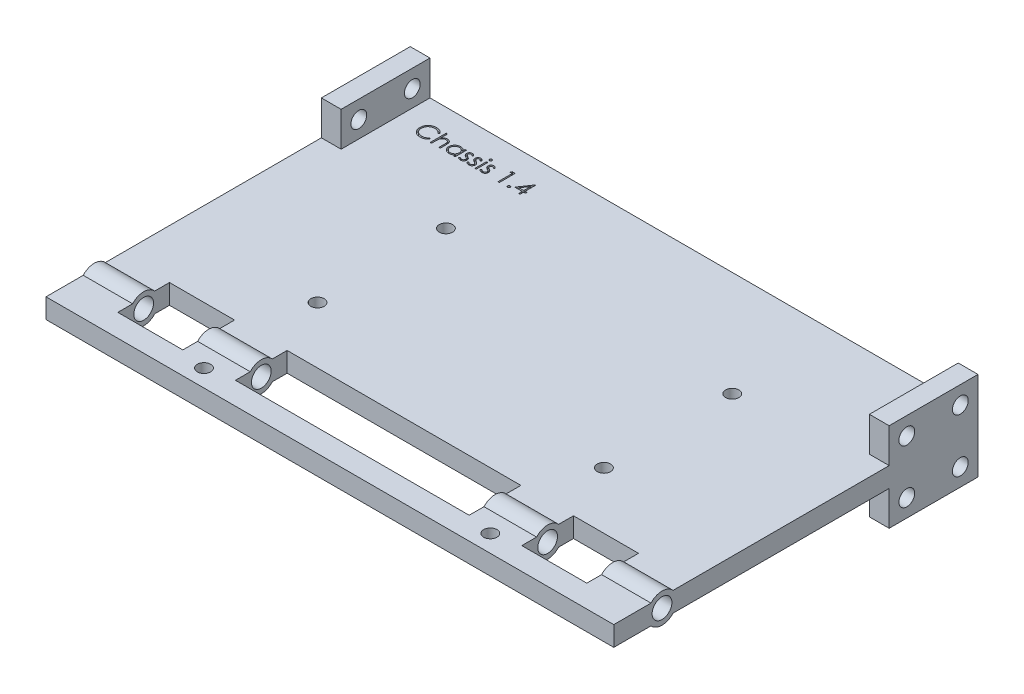
from build123d import *

# Parameters (mm, degrees)
SKETCH1_W           = 115
SKETCH1_H           = 73.776493944
SKETCH1_R           = 1.35
BASE_CHASSIS_DEPTH  = 2
SKETCH14_W          = 0.284935898
SKETCH14_H          = 2.320192308
TEXT_2_DEPTH        = 0.5
SKETCH7_W           = 18
SKETCH7_H           = 18
SKETCH7_R           = 1.6
MOUNT_HOLES_DEPTH   = 4
SKETCH8_R           = 3
SHAFT_EXTRUDE_DEPTH = 115
SKETCH20_R          = 2
SHAFT_CUT_DEPTH     = 116.0000001
SCREW_START         = -12
SCREW_HOLE_DEPTH    = 20


with BuildPart() as part:
    # Sketch1 → Base Chassis (new body, symmetric)
    with BuildSketch(Plane(origin=(0, 0, 0), x_dir=(1, 0, 0), z_dir=(0, 1, 0))):
        with Locations((57.5, -36.888246972)):
            Rectangle(SKETCH1_W, SKETCH1_H)
        with Locations((28.5, -47.276493944)):
            Circle(SKETCH1_R, mode=Mode.SUBTRACT)
        with Locations((28.5, -70.276493944)):
            Circle(SKETCH1_R, mode=Mode.SUBTRACT)
        with Locations((86.5, -47.276493944)):
            Circle(SKETCH1_R, mode=Mode.SUBTRACT)
        with Locations((86.5, -70.276493944)):
            Circle(SKETCH1_R, mode=Mode.SUBTRACT)
        with Locations((86.5, -21.276493944)):
            Circle(SKETCH1_R, mode=Mode.SUBTRACT)
        with Locations((28.5, -21.276493944)):
            Circle(SKETCH1_R, mode=Mode.SUBTRACT)
    extrude(amount=BASE_CHASSIS_DEPTH, both=True)

    # Sketch14 → Text 2 (cut)
    with BuildSketch(Plane(origin=(0, 2, 0), x_dir=(1, 0, 0), z_dir=(0, 1, 0))):
        with BuildLine():
            Line((11.257646665, -5.20350905), (11.008327754, -5.394314339))
            add(Edge.make_bspline(
                [(11.008327754, -5.394314339), (10.990542413, -5.373118066), (10.955211515, -5.331011293), (10.898370667, -5.271884134), (10.839132748, -5.216489219), (10.777520402, -5.164562656), (10.712424629, -5.117920305), (10.645422334, -5.074131518), (10.575392678, -5.034881499), (10.478553605, -4.987290076), (10.351873057, -4.937627492), (10.192402024, -4.895986704), (10.025931242, -4.869478923), (9.912359134, -4.86660796), (9.854591777, -4.865147672)],
                knots=[0, 0, 0, 0, 8.299e-05, 0.000164861, 0.000245858, 0.000326233, 0.000406381, 0.000485944, 0.000566254, 0.000647036, 0.000809554, 0.000973391, 0.001140702, 0.001313896, 0.001313896, 0.001313896, 0.001313896], degree=3))
            add(Edge.make_bspline(
                [(9.854591777, -4.865147672), (9.822766213, -4.865514124), (9.759410455, -4.866243626), (9.665386483, -4.875867618), (9.573118215, -4.889394216), (9.48266567, -4.909465045), (9.394143987, -4.934840207), (9.30697445, -4.965161832), (9.222419121, -5.00267658), (9.13930829, -5.044140501), (9.059680006, -5.090973969), (8.984337213, -5.142058224), (8.913554699, -5.196821618), (8.847276472, -5.255469408), (8.785434776, -5.317737472), (8.728477716, -5.38428941), (8.676602379, -5.454912454), (8.628780506, -5.52867533), (8.585951813, -5.605363184), (8.550092565, -5.685259855), (8.518337918, -5.766997149), (8.493210748, -5.851498559), (8.473322079, -5.938169496), (8.459599128, -6.027242568), (8.450084586, -6.118531692), (8.449358711, -6.180407283), (8.448992819, -6.211596991)],
                knots=[0, 0, 0, 0, 9.5437e-05, 0.000189987, 0.000283265, 0.000375086, 0.000467691, 0.000559419, 0.000651703, 0.000744998, 0.000837935, 0.000928607, 0.001017915, 0.001106228, 0.001193927, 0.001280987, 0.00136876, 0.001456615, 0.001544584, 0.001631962, 0.001719133, 0.001807466, 0.001896183, 0.00198569, 0.002077709, 0.002171238, 0.002171238, 0.002171238, 0.002171238], degree=3))
            add(Edge.make_bspline(
                [(8.448992819, -6.211596991), (8.450137469, -6.258524688), (8.452384837, -6.350660998), (8.472385826, -6.485617194), (8.50277973, -6.614903805), (8.548332432, -6.737712662), (8.604501857, -6.855558101), (8.675477269, -6.966446204), (8.757679413, -7.072052659), (8.852271208, -7.169881619), (8.956053627, -7.259247641), (9.067403518, -7.337942812), (9.186043551, -7.403542741), (9.310663779, -7.458130921), (9.442223183, -7.500092381), (9.580485182, -7.529632693), (9.725149063, -7.548902385), (9.823999876, -7.550747231), (9.874308323, -7.551686134)],
                knots=[0, 0, 0, 0, 0.000140704, 0.000276253, 0.000408455, 0.000538433, 0.000668431, 0.000799358, 0.000932567, 0.001069312, 0.00120687, 0.001342915, 0.001477586, 0.00161288, 0.00175046, 0.001891054, 0.002036604, 0.002187448, 0.002187448, 0.002187448, 0.002187448], degree=3))
            add(Edge.make_bspline(
                [(9.874308323, -7.551686134), (9.929737191, -7.550154169), (10.038834463, -7.547138897), (10.198825458, -7.521594435), (10.351983617, -7.480176181), (10.498317178, -7.422211637), (10.637413607, -7.346859554), (10.769490577, -7.255512194), (10.894659573, -7.147300635), (10.969926379, -7.064675226), (11.008327754, -7.022519467)],
                knots=[0, 0, 0, 0, 0.000166206, 0.000327134, 0.000484664, 0.00064139, 0.000798189, 0.000958205, 0.001122325, 0.001293282, 0.001293282, 0.001293282, 0.001293282], degree=3))
            Line((11.008327754, -7.022519467), (11.257646665, -7.211416703))
            add(Edge.make_bspline(
                [(11.257646665, -7.211416703), (11.237582379, -7.237305155), (11.197549915, -7.288958057), (11.132727286, -7.361775965), (11.064440023, -7.430268911), (10.992180915, -7.493884682), (10.916781204, -7.553896233), (10.836887035, -7.608598609), (10.753548698, -7.658755339), (10.667048564, -7.704681192), (10.577478536, -7.745427552), (10.484945942, -7.780310613), (10.389849634, -7.81035962), (10.292185266, -7.835081019), (10.191750258, -7.854376931), (10.088907042, -7.867276208), (9.983433655, -7.876113516), (9.91227608, -7.876918982), (9.876216376, -7.877327159)],
                knots=[0, 0, 0, 0, 9.8237e-05, 0.000196004, 0.000292247, 0.000388218, 0.000484669, 0.00058117, 0.000678466, 0.000776338, 0.000874822, 0.000973456, 0.001072826, 0.001173865, 0.001275526, 0.001379423, 0.001484691, 0.001592844, 0.001592844, 0.001592844, 0.001592844], degree=3))
            add(Edge.make_bspline(
                [(9.876216376, -7.877327159), (9.842068193, -7.877089495), (9.774544388, -7.876619542), (9.67485052, -7.869006647), (9.577795686, -7.8586201), (9.483657276, -7.842980839), (9.39192157, -7.824525616), (9.303420183, -7.79978669), (9.217282242, -7.772074232), (9.133853818, -7.73950328), (9.053063948, -7.702749314), (8.975173205, -7.661209829), (8.900217412, -7.615234137), (8.827459638, -7.565835663), (8.757974687, -7.511427682), (8.691160417, -7.452765807), (8.626642171, -7.390047754), (8.58672545, -7.34482228), (8.56665608, -7.32208377)],
                knots=[0, 0, 0, 0, 0.000102417, 0.000202516, 0.000299794, 0.000395154, 0.000488707, 0.000580357, 0.000670665, 0.000760075, 0.000848874, 0.000936794, 0.001024712, 0.001112565, 0.001200478, 0.001289268, 0.001379219, 0.001470177, 0.001470177, 0.001470177, 0.001470177], degree=3))
            add(Edge.make_bspline(
                [(8.56665608, -7.32208377), (8.534510889, -7.282585691), (8.470608592, -7.20406639), (8.388851722, -7.076806964), (8.318867868, -6.943939374), (8.262283997, -6.804765582), (8.218049232, -6.659597881), (8.187404862, -6.508363093), (8.167491621, -6.351202459), (8.165214431, -6.244307658), (8.164056921, -6.189972392)],
                knots=[0, 0, 0, 0, 0.000152677, 0.000303511, 0.000452867, 0.000602629, 0.000753527, 0.000907451, 0.001065071, 0.001228016, 0.001228016, 0.001228016, 0.001228016], degree=3))
            add(Edge.make_bspline(
                [(8.164056921, -6.189972392), (8.165467704, -6.132862802), (8.168243331, -6.020503249), (8.191825231, -5.855608305), (8.229760853, -5.697628108), (8.283642316, -5.546857568), (8.351955028, -5.402503671), (8.436343456, -5.265669149), (8.535827221, -5.13547891), (8.649626086, -5.013908385), (8.774419312, -4.902747687), (8.908058521, -4.804952059), (9.050282145, -4.723565455), (9.199523339, -4.655533222), (9.356899636, -4.603241459), (9.522075263, -4.566635354), (9.69473985, -4.543850542), (9.812543622, -4.540970175), (9.872400271, -4.539506646)],
                knots=[0, 0, 0, 0, 0.000171259, 0.000336941, 0.000498606, 0.000657931, 0.000816392, 0.000976852, 0.001139297, 0.001307149, 0.001475639, 0.001640004, 0.001802988, 0.001966374, 0.002131298, 0.002299486, 0.002473278, 0.002652798, 0.002652798, 0.002652798, 0.002652798], degree=3))
            add(Edge.make_bspline(
                [(9.872400271, -4.539506646), (9.908880541, -4.539944015), (9.981089564, -4.540809741), (10.087908042, -4.549251741), (10.19190501, -4.563324798), (10.293152115, -4.58248009), (10.392141917, -4.606253875), (10.488117849, -4.637224003), (10.581643087, -4.672635713), (10.672127782, -4.713419464), (10.759137795, -4.759200008), (10.842646027, -4.809469895), (10.921989149, -4.864166805), (10.997725461, -4.922825542), (11.068588024, -4.986687093), (11.136588794, -5.053994912), (11.199418487, -5.126687738), (11.238201742, -5.177855071), (11.257646665, -5.20350905)],
                knots=[0, 0, 0, 0, 0.000109425, 0.000216595, 0.000321206, 0.000424117, 0.000525619, 0.000626393, 0.000726442, 0.000825506, 0.000923941, 0.001021237, 0.001117738, 0.001212903, 0.001308399, 0.001403742, 0.001499772, 0.001596332, 0.001596332, 0.001596332, 0.001596332], degree=3))
        make_face()
        with BuildLine():
            Line((11.82751846, -4.539506646), (12.112454357, -4.539506646))
            Line((12.112454357, -4.539506646), (12.112454357, -5.913940741))
            add(Edge.make_bspline(
                [(12.112454357, -5.913940741), (12.143040766, -5.875710129), (12.202594073, -5.801273167), (12.302829836, -5.704153373), (12.405764127, -5.619971767), (12.514952204, -5.552960709), (12.628390891, -5.500022988), (12.746558625, -5.46247848), (12.869477363, -5.439390699), (12.952957321, -5.436489277), (12.995246825, -5.435019467)],
                knots=[0, 0, 0, 0, 0.000146744, 0.000285718, 0.000417826, 0.00054491, 0.000668979, 0.000792481, 0.000915983, 0.001042781, 0.001042781, 0.001042781, 0.001042781], degree=3))
            add(Edge.make_bspline(
                [(12.995246825, -5.435019467), (13.038182253, -5.436602822), (13.122217242, -5.439701828), (13.244573997, -5.464206824), (13.358838505, -5.506078214), (13.464671091, -5.56337973), (13.559762066, -5.634747223), (13.643990067, -5.71714439), (13.712788505, -5.812642873), (13.759596276, -5.900868189), (13.790052153, -5.979371202), (13.809330595, -6.046714324), (13.825676582, -6.121754916), (13.839918486, -6.204454352), (13.849410449, -6.295209615), (13.857034638, -6.39361126), (13.862456136, -6.499653645), (13.862666234, -6.573059872), (13.86277487, -6.611016062)],
                knots=[0, 0, 0, 0, 0.000128741, 0.000251978, 0.000372501, 0.000492599, 0.000611662, 0.000728143, 0.000844672, 0.000963309, 0.001026736, 0.001096978, 0.001173207, 0.001257065, 0.001348583, 0.001446826, 0.001553163, 0.001667017, 0.001667017, 0.001667017, 0.001667017], degree=3))
            Line((13.86277487, -6.611016062), (13.86277487, -7.795916903))
            Line((13.86277487, -7.795916903), (13.577838972, -7.795916903))
            Line((13.577838972, -7.795916903), (13.577838972, -6.704510653))
            add(Edge.make_bspline(
                [(13.577838972, -6.704510653), (13.57766634, -6.672921517), (13.577336124, -6.612496876), (13.576244519, -6.525986192), (13.573807738, -6.447521841), (13.569869989, -6.377355292), (13.565728603, -6.315388724), (13.560028736, -6.261712124), (13.55339731, -6.216251771), (13.547438487, -6.188888143), (13.544766056, -6.176616021)],
                knots=[0, 0, 0, 0, 9.4769e-05, 0.000181277, 0.000259548, 0.000330249, 0.000392103, 0.000445834, 0.000492159, 0.000529829, 0.000529829, 0.000529829, 0.000529829], degree=3))
            add(Edge.make_bspline(
                [(13.544766056, -6.176616021), (13.534402633, -6.140607654), (13.514479014, -6.071381776), (13.468171206, -5.977345162), (13.410332675, -5.897167575), (13.339714088, -5.831931043), (13.257564715, -5.780757718), (13.16334889, -5.745317658), (13.057953342, -5.72332151), (12.983702364, -5.721108713), (12.945001432, -5.719955364)],
                knots=[0, 0, 0, 0, 0.000112235, 0.000215771, 0.000312707, 0.000407219, 0.000502346, 0.000601207, 0.000707732, 0.000823699, 0.000823699, 0.000823699, 0.000823699], degree=3))
            add(Edge.make_bspline(
                [(12.945001432, -5.719955364), (12.922079952, -5.720387007), (12.876718936, -5.721241216), (12.809455503, -5.729817253), (12.744205567, -5.743831447), (12.680340734, -5.76279485), (12.619214548, -5.788599016), (12.559045282, -5.818471402), (12.501537678, -5.855036747), (12.445670544, -5.896062979), (12.393675353, -5.941483404), (12.345300041, -5.989423142), (12.302175975, -6.040472574), (12.263106611, -6.093812679), (12.229380594, -6.150175092), (12.199941013, -6.209016295), (12.174962202, -6.27041367), (12.162550046, -6.313026761), (12.156339573, -6.334348393)],
                knots=[0, 0, 0, 0, 6.8737e-05, 0.000136029, 0.000203016, 0.000268809, 0.000335543, 0.000401817, 0.000470111, 0.000539693, 0.000609577, 0.000677037, 0.000743816, 0.000809842, 0.000875179, 0.000940599, 0.001007093, 0.001073681, 0.001073681, 0.001073681, 0.001073681], degree=3))
            add(Edge.make_bspline(
                [(12.156339573, -6.334348393), (12.15276595, -6.349788827), (12.144978585, -6.383435434), (12.136528701, -6.438929285), (12.128965128, -6.503414779), (12.122571086, -6.576794109), (12.11864943, -6.659336165), (12.11442374, -6.750477678), (12.112850741, -6.850789554), (12.112590434, -6.920544764), (12.112454357, -6.957009651)],
                knots=[0, 0, 0, 0, 4.7531e-05, 0.000103577, 0.000168266, 0.000242318, 0.000324485, 0.000416151, 0.000516024, 0.000625421, 0.000625421, 0.000625421, 0.000625421], degree=3))
            Line((12.112454357, -6.957009651), (12.112454357, -7.795916903))
            Line((12.112454357, -7.795916903), (11.82751846, -7.795916903))
            Line((11.82751846, -7.795916903), (11.82751846, -4.539506646))
        make_face()
        with BuildLine():
            Line((16.874954357, -5.475724595), (16.874954357, -7.795916903))
            Line((16.874954357, -7.795916903), (16.59001846, -7.795916903))
            Line((16.59001846, -7.795916903), (16.59001846, -7.394589779))
            add(Edge.make_bspline(
                [(16.59001846, -7.394589779), (16.557888557, -7.430911411), (16.495186647, -7.501793532), (16.390465062, -7.594396646), (16.279459643, -7.670939837), (16.162709159, -7.732761547), (16.040319038, -7.779200055), (15.912560587, -7.812207499), (15.779381692, -7.83342905), (15.688438484, -7.835548155), (15.642352194, -7.836622031)],
                knots=[0, 0, 0, 0, 0.000145381, 0.000283713, 0.000418146, 0.000549018, 0.000679067, 0.000809885, 0.000944361, 0.001082524, 0.001082524, 0.001082524, 0.001082524], degree=3))
            add(Edge.make_bspline(
                [(15.642352194, -7.836622031), (15.601378407, -7.835509536), (15.520576285, -7.833315647), (15.401714194, -7.816295557), (15.28733051, -7.788962779), (15.177317148, -7.750952687), (15.072385988, -7.700532941), (14.971638614, -7.640170523), (14.875596958, -7.56828777), (14.785724919, -7.486111488), (14.702964461, -7.396853178), (14.63033745, -7.301652575), (14.56978287, -7.200921342), (14.519146083, -7.095934838), (14.480142256, -6.985884875), (14.452951888, -6.871152016), (14.435951625, -6.751871916), (14.433758643, -6.670646777), (14.432646665, -6.629460573)],
                knots=[0, 0, 0, 0, 0.000122885, 0.000242334, 0.00035942, 0.00047528, 0.000590784, 0.00070804, 0.000827103, 0.000950019, 0.001072896, 0.001191833, 0.001308545, 0.001424896, 0.001540967, 0.001658053, 0.001778133, 0.001901653, 0.001901653, 0.001901653, 0.001901653], degree=3))
            add(Edge.make_bspline(
                [(14.432646665, -6.629460573), (14.433783289, -6.589125642), (14.436030333, -6.509385659), (14.45277004, -6.392111411), (14.480919598, -6.279155561), (14.520423717, -6.170881762), (14.571080347, -6.067159002), (14.632700826, -5.967913922), (14.705289603, -5.872873112), (14.788975716, -5.784271356), (14.879630829, -5.70242837), (14.97661232, -5.631300165), (15.077507725, -5.569871309), (15.183882028, -5.521199941), (15.294160759, -5.481821682), (15.40932567, -5.45457749), (15.528897602, -5.438523491), (15.610078263, -5.436198698), (15.65125644, -5.435019467)],
                knots=[0, 0, 0, 0, 0.000120979, 0.000239169, 0.000354553, 0.000469642, 0.000584275, 0.000700235, 0.000819557, 0.000942401, 0.001065363, 0.001185447, 0.001302704, 0.001419089, 0.001535759, 0.001653464, 0.001773457, 0.001896977, 0.001896977, 0.001896977, 0.001896977], degree=3))
            add(Edge.make_bspline(
                [(15.65125644, -5.435019467), (15.69860917, -5.436323713), (15.791465637, -5.438881278), (15.927290331, -5.460165323), (16.055782107, -5.496123076), (16.177932841, -5.545033949), (16.293303892, -5.610029582), (16.400803028, -5.692017118), (16.501555288, -5.79047948), (16.559957409, -5.866108384), (16.59001846, -5.905036494)],
                knots=[0, 0, 0, 0, 0.000142004, 0.000278464, 0.000411172, 0.000541562, 0.000672282, 0.000807119, 0.000946093, 0.001093501, 0.001093501, 0.001093501, 0.001093501], degree=3))
            Line((16.59001846, -5.905036494), (16.59001846, -5.475724595))
            Line((16.59001846, -5.475724595), (16.874954357, -5.475724595))
        make_face()
        with BuildLine():
            add(Edge.make_bspline(
                [(15.655072546, -5.719955364), (15.613421683, -5.721437307), (15.531209503, -5.724362427), (15.410519586, -5.747198383), (15.295028132, -5.785193694), (15.185312765, -5.837156561), (15.083106597, -5.902496915), (14.991763053, -5.981528456), (14.910535031, -6.07209489), (14.842219677, -6.173787519), (14.786529726, -6.282806215), (14.747371061, -6.396765527), (14.721545387, -6.513610042), (14.718906943, -6.592860479), (14.717582562, -6.632640661)],
                knots=[0, 0, 0, 0, 0.000124893, 0.000246519, 0.000366995, 0.00048876, 0.000609786, 0.000729752, 0.00085002, 0.00097368, 0.001096273, 0.001216155, 0.001334406, 0.001453586, 0.001453586, 0.001453586, 0.001453586], degree=3))
            add(Edge.make_bspline(
                [(14.717582562, -6.632640661), (14.719274287, -6.672183115), (14.722651105, -6.751113031), (14.746917806, -6.86811684), (14.787630263, -6.982103007), (14.843185563, -7.092104051), (14.912751287, -7.194233913), (14.993385993, -7.286526739), (15.085869462, -7.365892294), (15.188310844, -7.432329236), (15.297719503, -7.485998094), (15.412775998, -7.52334121), (15.531317469, -7.547451053), (15.611919229, -7.550267257), (15.652528476, -7.551686134)],
                knots=[0, 0, 0, 0, 0.000118588, 0.000236711, 0.000356804, 0.000480819, 0.000605362, 0.000726581, 0.000847444, 0.000969696, 0.001092011, 0.001211883, 0.001331754, 0.001453472, 0.001453472, 0.001453472, 0.001453472], degree=3))
            add(Edge.make_bspline(
                [(15.652528476, -7.551686134), (15.693754946, -7.550180309), (15.775750307, -7.547185374), (15.896798277, -7.524251655), (16.014268708, -7.486361388), (16.126561408, -7.433838608), (16.231169613, -7.368744435), (16.325056973, -7.292538003), (16.404446459, -7.203907257), (16.471749754, -7.106501475), (16.524523168, -6.999719878), (16.562964308, -6.886023862), (16.585691779, -6.765409469), (16.588556291, -6.682982907), (16.59001846, -6.64090889)],
                knots=[0, 0, 0, 0, 0.000123623, 0.000245874, 0.000368165, 0.000493079, 0.000616791, 0.00073699, 0.000854515, 0.000972537, 0.001091147, 0.001210617, 0.001331618, 0.00145778, 0.00145778, 0.00145778, 0.00145778], degree=3))
            add(Edge.make_bspline(
                [(16.59001846, -6.64090889), (16.589147914, -6.60885243), (16.587434405, -6.545755171), (16.574343817, -6.453110923), (16.55352042, -6.364452471), (16.524177823, -6.279686603), (16.485632157, -6.199281982), (16.439143113, -6.122661285), (16.383893169, -6.050223015), (16.320771723, -5.982964658), (16.251679004, -5.921617796), (16.178568242, -5.866858806), (16.100573236, -5.821874705), (16.019005638, -5.784644409), (15.933723927, -5.755017894), (15.844034151, -5.735253343), (15.750889641, -5.721682195), (15.687347863, -5.720537035), (15.655072546, -5.719955364)],
                knots=[0, 0, 0, 0, 9.6142e-05, 0.000189237, 0.000280101, 0.000369007, 0.000457768, 0.000547103, 0.000637419, 0.000730567, 0.000823369, 0.000914322, 0.0010041, 0.001092899, 0.001183007, 0.001274346, 0.001368072, 0.001464822, 0.001464822, 0.001464822, 0.001464822], degree=3))
        make_face(mode=Mode.SUBTRACT)
        with BuildLine():
            Line((18.62527487, -5.765112616), (18.431925511, -5.964186134))
            add(Edge.make_bspline(
                [(18.431925511, -5.964186134), (18.415242697, -5.944852065), (18.383080196, -5.907578257), (18.332070209, -5.85774249), (18.281248798, -5.815889695), (18.23131166, -5.780554432), (18.181003087, -5.753839849), (18.130913454, -5.734340938), (18.080990898, -5.7222743), (18.047620709, -5.72071906), (18.031234405, -5.719955364)],
                knots=[0, 0, 0, 0, 7.6587e-05, 0.00014765, 0.000213612, 0.00027395, 0.000330855, 0.000384007, 0.00043492, 0.000484042, 0.000484042, 0.000484042, 0.000484042], degree=3))
            add(Edge.make_bspline(
                [(18.031234405, -5.719955364), (18.011150816, -5.720930428), (17.971629154, -5.722849214), (17.915000019, -5.742002112), (17.862430523, -5.771401468), (17.816930977, -5.81310154), (17.778388582, -5.860966269), (17.750254743, -5.914484364), (17.733049886, -5.972040804), (17.730868451, -6.011982175), (17.729762049, -6.03224002)],
                knots=[0, 0, 0, 0, 6.0059e-05, 0.000118188, 0.000177433, 0.0002396, 0.000302079, 0.000360968, 0.00041994, 0.000480632, 0.000480632, 0.000480632, 0.000480632], degree=3))
            add(Edge.make_bspline(
                [(17.729762049, -6.03224002), (17.730769715, -6.050575231), (17.732782205, -6.087193968), (17.748427407, -6.141212541), (17.773343058, -6.193878569), (17.796629591, -6.226139205), (17.808628235, -6.242761855)],
                knots=[0, 0, 0, 0, 5.4934e-05, 0.000109712, 0.000167464, 0.000228852, 0.000228852, 0.000228852, 0.000228852], degree=3))
            add(Edge.make_bspline(
                [(17.808628235, -6.242761855), (17.815852262, -6.251637871), (17.831227692, -6.270529352), (17.860082559, -6.296749276), (17.892760115, -6.32572546), (17.932057487, -6.354696734), (17.976281634, -6.385205513), (18.026391556, -6.416050305), (18.080797, -6.449582319), (18.119747271, -6.470849772), (18.13999342, -6.481904483)],
                knots=[0, 0, 0, 0, 3.4286e-05, 7.2973e-05, 0.000116711, 0.000165303, 0.000219286, 0.000277872, 0.000341791, 0.00041098, 0.00041098, 0.00041098, 0.00041098], degree=3))
            add(Edge.make_bspline(
                [(18.13999342, -6.481904483), (18.164680022, -6.495733788), (18.212366408, -6.522447451), (18.280123418, -6.563912682), (18.341615948, -6.605125474), (18.397365018, -6.645645072), (18.446297945, -6.686605174), (18.489899361, -6.726435782), (18.527081735, -6.766340368), (18.547904225, -6.794219693), (18.557857001, -6.807545509)],
                knots=[0, 0, 0, 0, 8.4884e-05, 0.000163968, 0.000238232, 0.000306925, 0.000370606, 0.000429564, 0.000484028, 0.000533898, 0.000533898, 0.000533898, 0.000533898], degree=3))
            add(Edge.make_bspline(
                [(18.557857001, -6.807545509), (18.574376551, -6.834456889), (18.607253521, -6.888015529), (18.641777806, -6.976206531), (18.661789627, -7.069742487), (18.664567498, -7.133725287), (18.665979998, -7.166259451)],
                knots=[0, 0, 0, 0, 9.4587e-05, 0.000188246, 0.000282553, 0.000380115, 0.000380115, 0.000380115, 0.000380115], degree=3))
            add(Edge.make_bspline(
                [(18.665979998, -7.166259451), (18.665327278, -7.189182176), (18.664041022, -7.234353911), (18.655098347, -7.300879078), (18.639717761, -7.364501141), (18.618768428, -7.425910435), (18.590479746, -7.48393033), (18.557325673, -7.540024642), (18.51752486, -7.592979951), (18.472084827, -7.642726722), (18.422332129, -7.68816165), (18.369258703, -7.728097665), (18.312799193, -7.761275814), (18.253357023, -7.788730805), (18.190797137, -7.810564154), (18.125109753, -7.82567945), (18.056503668, -7.834726169), (18.009849485, -7.835982087), (17.986077154, -7.836622031)],
                knots=[0, 0, 0, 0, 6.8763e-05, 0.000135506, 0.000200914, 0.000264877, 0.000329738, 0.000394202, 0.000460094, 0.000528077, 0.000596059, 0.000661951, 0.000726961, 0.000792128, 0.000858102, 0.000925367, 0.000994001, 0.001065306, 0.001065306, 0.001065306, 0.001065306], degree=3))
            add(Edge.make_bspline(
                [(17.986077154, -7.836622031), (17.953994073, -7.83572151), (17.890273704, -7.833932981), (17.796030887, -7.81714534), (17.703937056, -7.791023804), (17.61468913, -7.754995778), (17.530283012, -7.709501917), (17.453057102, -7.655016745), (17.382743133, -7.593340105), (17.342721556, -7.54606625), (17.322710767, -7.522429323)],
                knots=[0, 0, 0, 0, 9.6173e-05, 0.00019101, 0.000286237, 0.000382966, 0.000479156, 0.000573205, 0.000666007, 0.000758809, 0.000758809, 0.000758809, 0.000758809], degree=3))
            Line((17.322710767, -7.522429323), (17.511608003, -7.307455364))
            add(Edge.make_bspline(
                [(17.511608003, -7.307455364), (17.529544406, -7.326827187), (17.564316836, -7.364382393), (17.619925797, -7.414388045), (17.676512825, -7.456299198), (17.733512862, -7.491354295), (17.791769662, -7.51836484), (17.850956755, -7.537340993), (17.910953754, -7.549536796), (17.951250977, -7.550968523), (17.971448748, -7.551686134)],
                knots=[0, 0, 0, 0, 7.9173e-05, 0.000153489, 0.000223961, 0.000290171, 0.000353916, 0.000416067, 0.000476314, 0.000536856, 0.000536856, 0.000536856, 0.000536856], degree=3))
            add(Edge.make_bspline(
                [(17.971448748, -7.551686134), (17.998951438, -7.5504426), (18.052687081, -7.548012943), (18.12965249, -7.525953867), (18.200716816, -7.491364553), (18.262423708, -7.442302005), (18.31494924, -7.385192307), (18.352984084, -7.320863071), (18.376820328, -7.251202249), (18.37961977, -7.202912946), (18.381044101, -7.178343786)],
                knots=[0, 0, 0, 0, 8.2344e-05, 0.000160886, 0.000238253, 0.000318022, 0.000395931, 0.000469778, 0.000540776, 0.000614315, 0.000614315, 0.000614315, 0.000614315], degree=3))
            add(Edge.make_bspline(
                [(18.381044101, -7.178343786), (18.380058676, -7.158105775), (18.378113088, -7.118148531), (18.362833835, -7.060317864), (18.338692176, -7.005463588), (18.314920816, -6.973360122), (18.302813932, -6.957009651)],
                knots=[0, 0, 0, 0, 6.0636e-05, 0.000119717, 0.000178355, 0.000239217, 0.000239217, 0.000239217, 0.000239217], degree=3))
            add(Edge.make_bspline(
                [(18.302813932, -6.957009651), (18.295536475, -6.948813287), (18.279683543, -6.930958646), (18.25060486, -6.905173038), (18.215787028, -6.877379905), (18.174838451, -6.848050535), (18.127676582, -6.817571801), (18.074110273, -6.786103603), (18.014873343, -6.752151308), (17.972989984, -6.729636335), (17.951096184, -6.717867023)],
                knots=[0, 0, 0, 0, 3.2858e-05, 7.1577e-05, 0.000116374, 0.000166503, 0.000222602, 0.000284776, 0.000352857, 0.000427423, 0.000427423, 0.000427423, 0.000427423], degree=3))
            add(Edge.make_bspline(
                [(17.951096184, -6.717867023), (17.927468161, -6.704677954), (17.881645882, -6.679100139), (17.816742269, -6.63926198), (17.758188597, -6.598742381), (17.704575933, -6.559814306), (17.657258449, -6.520425306), (17.616422553, -6.480531657), (17.580460493, -6.441742241), (17.560551056, -6.414258265), (17.551041096, -6.401130244)],
                knots=[0, 0, 0, 0, 8.1176e-05, 0.000157427, 0.000228345, 0.000294747, 0.000356148, 0.000412822, 0.000465959, 0.000514551, 0.000514551, 0.000514551, 0.000514551], degree=3))
            add(Edge.make_bspline(
                [(17.551041096, -6.401130244), (17.534594052, -6.374691008), (17.501694216, -6.321803295), (17.469749007, -6.233528791), (17.447790681, -6.140596489), (17.445829084, -6.076473414), (17.444826152, -6.043688337)],
                knots=[0, 0, 0, 0, 9.3167e-05, 0.000186367, 0.000280188, 0.000378341, 0.000378341, 0.000378341, 0.000378341], degree=3))
            add(Edge.make_bspline(
                [(17.444826152, -6.043688337), (17.445310743, -6.022256726), (17.446259158, -5.980312027), (17.453828404, -5.918681812), (17.467609457, -5.860127415), (17.484894994, -5.803769475), (17.508918862, -5.750699718), (17.537626219, -5.700210441), (17.571360526, -5.652371429), (17.610225511, -5.607918588), (17.652957968, -5.567542271), (17.699126794, -5.532346373), (17.747693641, -5.502314179), (17.798864136, -5.477127212), (17.853129851, -5.458075958), (17.910111473, -5.444961044), (17.969693664, -5.436202396), (18.010425399, -5.435419455), (18.031234405, -5.435019467)],
                knots=[0, 0, 0, 0, 6.4288e-05, 0.000125821, 0.00018584, 0.000244574, 0.000302371, 0.000360196, 0.000418606, 0.00047766, 0.000537052, 0.000594677, 0.000651511, 0.000708117, 0.000765447, 0.000823607, 0.000883331, 0.000945713, 0.000945713, 0.000945713, 0.000945713], degree=3))
            add(Edge.make_bspline(
                [(18.031234405, -5.435019467), (18.055901491, -5.436021262), (18.105698392, -5.438043644), (18.180405803, -5.454105235), (18.255003192, -5.480533122), (18.329682231, -5.517033134), (18.403895851, -5.564265228), (18.478296856, -5.621351093), (18.553778427, -5.687915162), (18.600910225, -5.738805174), (18.62527487, -5.765112616)],
                knots=[0, 0, 0, 0, 7.3953e-05, 0.000149294, 0.000228145, 0.00031092, 0.000398091, 0.000491588, 0.000592049, 0.000699558, 0.000699558, 0.000699558, 0.000699558], degree=3))
        make_face()
        with BuildLine():
            Line((20.334890254, -5.765112616), (20.141540896, -5.964186134))
            add(Edge.make_bspline(
                [(20.141540896, -5.964186134), (20.124858082, -5.944852065), (20.09269558, -5.907578257), (20.041685594, -5.85774249), (19.990864182, -5.815889695), (19.940927044, -5.780554432), (19.890618472, -5.753839849), (19.840528839, -5.734340938), (19.790606283, -5.7222743), (19.757236094, -5.72071906), (19.74084979, -5.719955364)],
                knots=[0, 0, 0, 0, 7.6587e-05, 0.00014765, 0.000213612, 0.00027395, 0.000330855, 0.000384007, 0.00043492, 0.000484042, 0.000484042, 0.000484042, 0.000484042], degree=3))
            add(Edge.make_bspline(
                [(19.74084979, -5.719955364), (19.7207662, -5.720930428), (19.681244539, -5.722849214), (19.624615404, -5.742002112), (19.572045908, -5.771401468), (19.526546362, -5.81310154), (19.488003967, -5.860966269), (19.459870127, -5.914484364), (19.442665271, -5.972040804), (19.440483835, -6.011982175), (19.439377434, -6.03224002)],
                knots=[0, 0, 0, 0, 6.0059e-05, 0.000118188, 0.000177433, 0.0002396, 0.000302079, 0.000360968, 0.00041994, 0.000480632, 0.000480632, 0.000480632, 0.000480632], degree=3))
            add(Edge.make_bspline(
                [(19.439377434, -6.03224002), (19.440385099, -6.050575231), (19.44239759, -6.087193968), (19.458042791, -6.141212541), (19.482958443, -6.193878569), (19.506244976, -6.226139205), (19.51824362, -6.242761855)],
                knots=[0, 0, 0, 0, 5.4934e-05, 0.000109712, 0.000167464, 0.000228852, 0.000228852, 0.000228852, 0.000228852], degree=3))
            add(Edge.make_bspline(
                [(19.51824362, -6.242761855), (19.525467646, -6.251637871), (19.540843076, -6.270529352), (19.569697943, -6.296749276), (19.6023755, -6.32572546), (19.641672872, -6.354696734), (19.685897018, -6.385205513), (19.736006941, -6.416050305), (19.790412384, -6.449582319), (19.829362655, -6.470849772), (19.849608804, -6.481904483)],
                knots=[0, 0, 0, 0, 3.4286e-05, 7.2973e-05, 0.000116711, 0.000165303, 0.000219286, 0.000277872, 0.000341791, 0.00041098, 0.00041098, 0.00041098, 0.00041098], degree=3))
            add(Edge.make_bspline(
                [(19.849608804, -6.481904483), (19.874295406, -6.495733788), (19.921981793, -6.522447451), (19.989738803, -6.563912682), (20.051231333, -6.605125474), (20.106980403, -6.645645072), (20.15591333, -6.686605174), (20.199514745, -6.726435782), (20.236697119, -6.766340368), (20.25751961, -6.794219693), (20.267472386, -6.807545509)],
                knots=[0, 0, 0, 0, 8.4884e-05, 0.000163968, 0.000238232, 0.000306925, 0.000370606, 0.000429564, 0.000484028, 0.000533898, 0.000533898, 0.000533898, 0.000533898], degree=3))
            add(Edge.make_bspline(
                [(20.267472386, -6.807545509), (20.283991936, -6.834456889), (20.316868906, -6.888015529), (20.351393191, -6.976206531), (20.371405011, -7.069742487), (20.374182882, -7.133725287), (20.375595383, -7.166259451)],
                knots=[0, 0, 0, 0, 9.4587e-05, 0.000188246, 0.000282553, 0.000380115, 0.000380115, 0.000380115, 0.000380115], degree=3))
            add(Edge.make_bspline(
                [(20.375595383, -7.166259451), (20.374942663, -7.189182176), (20.373656407, -7.234353911), (20.364713732, -7.300879078), (20.349333146, -7.364501141), (20.328383812, -7.425910435), (20.300095131, -7.48393033), (20.266941058, -7.540024642), (20.227140245, -7.592979951), (20.181700211, -7.642726722), (20.131947513, -7.68816165), (20.078874088, -7.728097665), (20.022414577, -7.761275814), (19.962972407, -7.788730805), (19.900412521, -7.810564154), (19.834725137, -7.82567945), (19.766119053, -7.834726169), (19.71946487, -7.835982087), (19.695692538, -7.836622031)],
                knots=[0, 0, 0, 0, 6.8763e-05, 0.000135506, 0.000200914, 0.000264877, 0.000329738, 0.000394202, 0.000460094, 0.000528077, 0.000596059, 0.000661951, 0.000726961, 0.000792128, 0.000858102, 0.000925367, 0.000994001, 0.001065306, 0.001065306, 0.001065306, 0.001065306], degree=3))
            add(Edge.make_bspline(
                [(19.695692538, -7.836622031), (19.663609458, -7.83572151), (19.599889088, -7.833932981), (19.505646271, -7.81714534), (19.41355244, -7.791023804), (19.324304515, -7.754995778), (19.239898397, -7.709501917), (19.162672487, -7.655016745), (19.092358517, -7.593340105), (19.05233694, -7.54606625), (19.032326152, -7.522429323)],
                knots=[0, 0, 0, 0, 9.6173e-05, 0.00019101, 0.000286237, 0.000382966, 0.000479156, 0.000573205, 0.000666007, 0.000758809, 0.000758809, 0.000758809, 0.000758809], degree=3))
            Line((19.032326152, -7.522429323), (19.221223387, -7.307455364))
            add(Edge.make_bspline(
                [(19.221223387, -7.307455364), (19.239159791, -7.326827187), (19.27393222, -7.364382393), (19.329541181, -7.414388045), (19.386128209, -7.456299198), (19.443128247, -7.491354295), (19.501385046, -7.51836484), (19.560572139, -7.537340993), (19.620569138, -7.549536796), (19.660866361, -7.550968523), (19.681064133, -7.551686134)],
                knots=[0, 0, 0, 0, 7.9173e-05, 0.000153489, 0.000223961, 0.000290171, 0.000353916, 0.000416067, 0.000476314, 0.000536856, 0.000536856, 0.000536856, 0.000536856], degree=3))
            add(Edge.make_bspline(
                [(19.681064133, -7.551686134), (19.708566823, -7.5504426), (19.762302465, -7.548012943), (19.839267875, -7.525953867), (19.9103322, -7.491364553), (19.972039092, -7.442302005), (20.024564624, -7.385192307), (20.062599468, -7.320863071), (20.086435713, -7.251202249), (20.089235155, -7.202912946), (20.090659485, -7.178343786)],
                knots=[0, 0, 0, 0, 8.2344e-05, 0.000160886, 0.000238253, 0.000318022, 0.000395931, 0.000469778, 0.000540776, 0.000614315, 0.000614315, 0.000614315, 0.000614315], degree=3))
            add(Edge.make_bspline(
                [(20.090659485, -7.178343786), (20.089674061, -7.158105775), (20.087728473, -7.118148531), (20.072449219, -7.060317864), (20.04830756, -7.005463588), (20.024536201, -6.973360122), (20.012429317, -6.957009651)],
                knots=[0, 0, 0, 0, 6.0636e-05, 0.000119717, 0.000178355, 0.000239217, 0.000239217, 0.000239217, 0.000239217], degree=3))
            add(Edge.make_bspline(
                [(20.012429317, -6.957009651), (20.005151859, -6.948813287), (19.989298928, -6.930958646), (19.960220245, -6.905173038), (19.925402412, -6.877379905), (19.884453836, -6.848050535), (19.837291967, -6.817571801), (19.783725657, -6.786103603), (19.724488727, -6.752151308), (19.682605369, -6.729636335), (19.660711569, -6.717867023)],
                knots=[0, 0, 0, 0, 3.2858e-05, 7.1577e-05, 0.000116374, 0.000166503, 0.000222602, 0.000284776, 0.000352857, 0.000427423, 0.000427423, 0.000427423, 0.000427423], degree=3))
            add(Edge.make_bspline(
                [(19.660711569, -6.717867023), (19.637083545, -6.704677954), (19.591261267, -6.679100139), (19.526357653, -6.63926198), (19.467803982, -6.598742381), (19.414191318, -6.559814306), (19.366873834, -6.520425306), (19.326037938, -6.480531657), (19.290075878, -6.441742241), (19.27016644, -6.414258265), (19.26065648, -6.401130244)],
                knots=[0, 0, 0, 0, 8.1176e-05, 0.000157427, 0.000228345, 0.000294747, 0.000356148, 0.000412822, 0.000465959, 0.000514551, 0.000514551, 0.000514551, 0.000514551], degree=3))
            add(Edge.make_bspline(
                [(19.26065648, -6.401130244), (19.244209436, -6.374691008), (19.211309601, -6.321803295), (19.179364392, -6.233528791), (19.157406066, -6.140596489), (19.155444469, -6.076473414), (19.154441537, -6.043688337)],
                knots=[0, 0, 0, 0, 9.3167e-05, 0.000186367, 0.000280188, 0.000378341, 0.000378341, 0.000378341, 0.000378341], degree=3))
            add(Edge.make_bspline(
                [(19.154441537, -6.043688337), (19.154926128, -6.022256726), (19.155874542, -5.980312027), (19.163443789, -5.918681812), (19.177224841, -5.860127415), (19.194510378, -5.803769475), (19.218534247, -5.750699718), (19.247241603, -5.700210441), (19.28097591, -5.652371429), (19.319840895, -5.607918588), (19.362573352, -5.567542271), (19.408742179, -5.532346373), (19.457309026, -5.502314179), (19.508479521, -5.477127212), (19.562745236, -5.458075958), (19.619726858, -5.444961044), (19.679309048, -5.436202396), (19.720040784, -5.435419455), (19.74084979, -5.435019467)],
                knots=[0, 0, 0, 0, 6.4288e-05, 0.000125821, 0.00018584, 0.000244574, 0.000302371, 0.000360196, 0.000418606, 0.00047766, 0.000537052, 0.000594677, 0.000651511, 0.000708117, 0.000765447, 0.000823607, 0.000883331, 0.000945713, 0.000945713, 0.000945713, 0.000945713], degree=3))
            add(Edge.make_bspline(
                [(19.74084979, -5.435019467), (19.765516876, -5.436021262), (19.815313777, -5.438043644), (19.890021188, -5.454105235), (19.964618577, -5.480533122), (20.039297616, -5.517033134), (20.113511235, -5.564265228), (20.187912241, -5.621351093), (20.263393811, -5.687915162), (20.31052561, -5.738805174), (20.334890254, -5.765112616)],
                knots=[0, 0, 0, 0, 7.3953e-05, 0.000149294, 0.000228145, 0.00031092, 0.000398091, 0.000491588, 0.000592049, 0.000699558, 0.000699558, 0.000699558, 0.000699558], degree=3))
        make_face()
        with BuildLine():
            add(Edge.make_bspline(
                [(21.045957963, -4.498801518), (21.063639371, -4.499621714), (21.098262963, -4.501227814), (21.148331142, -4.514981439), (21.193921431, -4.538294725), (21.234359803, -4.569572722), (21.269059729, -4.60635686), (21.293353659, -4.64922931), (21.308967761, -4.695546789), (21.310853308, -4.727854763), (21.311813331, -4.744304323)],
                knots=[0, 0, 0, 0, 5.2977e-05, 0.000103739, 0.000154369, 0.000205635, 0.000256504, 0.000304942, 0.000352409, 0.000401646, 0.000401646, 0.000401646, 0.000401646], degree=3))
            add(Edge.make_bspline(
                [(21.311813331, -4.744304323), (21.310831658, -4.760326872), (21.308891005, -4.792001557), (21.29336572, -4.837516064), (21.26885269, -4.879792807), (21.234382054, -4.916505522), (21.193915535, -4.947766228), (21.148332708, -4.971084098), (21.098262551, -4.984836508), (21.063639231, -4.986442776), (21.045957963, -4.987263057)],
                knots=[0, 0, 0, 0, 4.7972e-05, 9.4835e-05, 0.000142722, 0.000193592, 0.000244857, 0.000295488, 0.00034625, 0.000399227, 0.000399227, 0.000399227, 0.000399227], degree=3))
            add(Edge.make_bspline(
                [(21.045957963, -4.987263057), (21.028478885, -4.986474096), (20.994458143, -4.984938488), (20.94513965, -4.970814257), (20.899938092, -4.947758248), (20.859420853, -4.916710209), (20.825647749, -4.879567338), (20.801065697, -4.837541864), (20.785576267, -4.791994988), (20.783630783, -4.760324666), (20.782646665, -4.744304323)],
                knots=[0, 0, 0, 0, 5.2343e-05, 0.000101879, 0.000152509, 0.000203775, 0.000254217, 0.000302105, 0.000348968, 0.00039694, 0.00039694, 0.00039694, 0.00039694], degree=3))
            add(Edge.make_bspline(
                [(20.782646665, -4.744304323), (20.783609222, -4.727857052), (20.785499745, -4.695553575), (20.801077307, -4.64920308), (20.82544299, -4.606584147), (20.859443216, -4.569368158), (20.89993214, -4.538302656), (20.945141188, -4.515251266), (20.994457736, -4.501125837), (21.028478747, -4.499590394), (21.045957963, -4.498801518)],
                knots=[0, 0, 0, 0, 4.9237e-05, 9.6705e-05, 0.000145142, 0.000195584, 0.00024685, 0.00029748, 0.000347016, 0.000399359, 0.000399359, 0.000399359, 0.000399359], degree=3))
        make_face()
        with Locations((21.047229998, -6.635820749)):
            Rectangle(SKETCH14_W, SKETCH14_H)
        with BuildLine():
            Line((22.980723588, -5.765112616), (22.787374229, -5.964186134))
            add(Edge.make_bspline(
                [(22.787374229, -5.964186134), (22.770691415, -5.944852065), (22.738528914, -5.907578257), (22.687518927, -5.85774249), (22.636697516, -5.815889695), (22.586760377, -5.780554432), (22.536451805, -5.753839849), (22.486362172, -5.734340938), (22.436439616, -5.7222743), (22.403069427, -5.72071906), (22.386683123, -5.719955364)],
                knots=[0, 0, 0, 0, 7.6587e-05, 0.00014765, 0.000213612, 0.00027395, 0.000330855, 0.000384007, 0.00043492, 0.000484042, 0.000484042, 0.000484042, 0.000484042], degree=3))
            add(Edge.make_bspline(
                [(22.386683123, -5.719955364), (22.366599534, -5.720930428), (22.327077872, -5.722849214), (22.270448737, -5.742002112), (22.217879241, -5.771401468), (22.172379695, -5.81310154), (22.1338373, -5.860966269), (22.105703461, -5.914484364), (22.088498604, -5.972040804), (22.086317169, -6.011982175), (22.085210767, -6.03224002)],
                knots=[0, 0, 0, 0, 6.0059e-05, 0.000118188, 0.000177433, 0.0002396, 0.000302079, 0.000360968, 0.00041994, 0.000480632, 0.000480632, 0.000480632, 0.000480632], degree=3))
            add(Edge.make_bspline(
                [(22.085210767, -6.03224002), (22.086218433, -6.050575231), (22.088230923, -6.087193968), (22.103876125, -6.141212541), (22.128791776, -6.193878569), (22.152078309, -6.226139205), (22.164076953, -6.242761855)],
                knots=[0, 0, 0, 0, 5.4934e-05, 0.000109712, 0.000167464, 0.000228852, 0.000228852, 0.000228852, 0.000228852], degree=3))
            add(Edge.make_bspline(
                [(22.164076953, -6.242761855), (22.17130098, -6.251637871), (22.18667641, -6.270529352), (22.215531277, -6.296749276), (22.248208833, -6.32572546), (22.287506205, -6.354696734), (22.331730352, -6.385205513), (22.381840274, -6.416050305), (22.436245718, -6.449582319), (22.475195989, -6.470849772), (22.495442137, -6.481904483)],
                knots=[0, 0, 0, 0, 3.4286e-05, 7.2973e-05, 0.000116711, 0.000165303, 0.000219286, 0.000277872, 0.000341791, 0.00041098, 0.00041098, 0.00041098, 0.00041098], degree=3))
            add(Edge.make_bspline(
                [(22.495442137, -6.481904483), (22.52012874, -6.495733788), (22.567815126, -6.522447451), (22.635572136, -6.563912682), (22.697064666, -6.605125474), (22.752813736, -6.645645072), (22.801746663, -6.686605174), (22.845348078, -6.726435782), (22.882530453, -6.766340368), (22.903352943, -6.794219693), (22.913305719, -6.807545509)],
                knots=[0, 0, 0, 0, 8.4884e-05, 0.000163968, 0.000238232, 0.000306925, 0.000370606, 0.000429564, 0.000484028, 0.000533898, 0.000533898, 0.000533898, 0.000533898], degree=3))
            add(Edge.make_bspline(
                [(22.913305719, -6.807545509), (22.929825269, -6.834456889), (22.962702239, -6.888015529), (22.997226524, -6.976206531), (23.017238345, -7.069742487), (23.020016216, -7.133725287), (23.021428716, -7.166259451)],
                knots=[0, 0, 0, 0, 9.4587e-05, 0.000188246, 0.000282553, 0.000380115, 0.000380115, 0.000380115, 0.000380115], degree=3))
            add(Edge.make_bspline(
                [(23.021428716, -7.166259451), (23.020775996, -7.189182176), (23.01948974, -7.234353911), (23.010547065, -7.300879078), (22.995166479, -7.364501141), (22.974217145, -7.425910435), (22.945928464, -7.48393033), (22.912774391, -7.540024642), (22.872973578, -7.592979951), (22.827533545, -7.642726722), (22.777780847, -7.68816165), (22.724707421, -7.728097665), (22.668247911, -7.761275814), (22.608805741, -7.788730805), (22.546245855, -7.810564154), (22.480558471, -7.82567945), (22.411952386, -7.834726169), (22.365298203, -7.835982087), (22.341525871, -7.836622031)],
                knots=[0, 0, 0, 0, 6.8763e-05, 0.000135506, 0.000200914, 0.000264877, 0.000329738, 0.000394202, 0.000460094, 0.000528077, 0.000596059, 0.000661951, 0.000726961, 0.000792128, 0.000858102, 0.000925367, 0.000994001, 0.001065306, 0.001065306, 0.001065306, 0.001065306], degree=3))
            add(Edge.make_bspline(
                [(22.341525871, -7.836622031), (22.309442791, -7.83572151), (22.245722421, -7.833932981), (22.151479605, -7.81714534), (22.059385774, -7.791023804), (21.970137848, -7.754995778), (21.88573173, -7.709501917), (21.80850582, -7.655016745), (21.738191851, -7.593340105), (21.698170274, -7.54606625), (21.678159485, -7.522429323)],
                knots=[0, 0, 0, 0, 9.6173e-05, 0.00019101, 0.000286237, 0.000382966, 0.000479156, 0.000573205, 0.000666007, 0.000758809, 0.000758809, 0.000758809, 0.000758809], degree=3))
            Line((21.678159485, -7.522429323), (21.867056721, -7.307455364))
            add(Edge.make_bspline(
                [(21.867056721, -7.307455364), (21.884993124, -7.326827187), (21.919765554, -7.364382393), (21.975374515, -7.414388045), (22.031961543, -7.456299198), (22.08896158, -7.491354295), (22.14721838, -7.51836484), (22.206405473, -7.537340993), (22.266402472, -7.549536796), (22.306699695, -7.550968523), (22.326897466, -7.551686134)],
                knots=[0, 0, 0, 0, 7.9173e-05, 0.000153489, 0.000223961, 0.000290171, 0.000353916, 0.000416067, 0.000476314, 0.000536856, 0.000536856, 0.000536856, 0.000536856], degree=3))
            add(Edge.make_bspline(
                [(22.326897466, -7.551686134), (22.354400156, -7.5504426), (22.408135799, -7.548012943), (22.485101208, -7.525953867), (22.556165534, -7.491364553), (22.617872426, -7.442302005), (22.670397958, -7.385192307), (22.708432802, -7.320863071), (22.732269046, -7.251202249), (22.735068488, -7.202912946), (22.736492819, -7.178343786)],
                knots=[0, 0, 0, 0, 8.2344e-05, 0.000160886, 0.000238253, 0.000318022, 0.000395931, 0.000469778, 0.000540776, 0.000614315, 0.000614315, 0.000614315, 0.000614315], degree=3))
            add(Edge.make_bspline(
                [(22.736492819, -7.178343786), (22.735507394, -7.158105775), (22.733561806, -7.118148531), (22.718282552, -7.060317864), (22.694140894, -7.005463588), (22.670369534, -6.973360122), (22.65826265, -6.957009651)],
                knots=[0, 0, 0, 0, 6.0636e-05, 0.000119717, 0.000178355, 0.000239217, 0.000239217, 0.000239217, 0.000239217], degree=3))
            add(Edge.make_bspline(
                [(22.65826265, -6.957009651), (22.650985193, -6.948813287), (22.635132261, -6.930958646), (22.606053578, -6.905173038), (22.571235746, -6.877379905), (22.530287169, -6.848050535), (22.4831253, -6.817571801), (22.429558991, -6.786103603), (22.370322061, -6.752151308), (22.328438702, -6.729636335), (22.306544902, -6.717867023)],
                knots=[0, 0, 0, 0, 3.2858e-05, 7.1577e-05, 0.000116374, 0.000166503, 0.000222602, 0.000284776, 0.000352857, 0.000427423, 0.000427423, 0.000427423, 0.000427423], degree=3))
            add(Edge.make_bspline(
                [(22.306544902, -6.717867023), (22.282916878, -6.704677954), (22.2370946, -6.679100139), (22.172190986, -6.63926198), (22.113637315, -6.598742381), (22.060024651, -6.559814306), (22.012707167, -6.520425306), (21.971871271, -6.480531657), (21.935909211, -6.441742241), (21.915999774, -6.414258265), (21.906489814, -6.401130244)],
                knots=[0, 0, 0, 0, 8.1176e-05, 0.000157427, 0.000228345, 0.000294747, 0.000356148, 0.000412822, 0.000465959, 0.000514551, 0.000514551, 0.000514551, 0.000514551], degree=3))
            add(Edge.make_bspline(
                [(21.906489814, -6.401130244), (21.89004277, -6.374691008), (21.857142934, -6.321803295), (21.825197725, -6.233528791), (21.803239399, -6.140596489), (21.801277802, -6.076473414), (21.80027487, -6.043688337)],
                knots=[0, 0, 0, 0, 9.3167e-05, 0.000186367, 0.000280188, 0.000378341, 0.000378341, 0.000378341, 0.000378341], degree=3))
            add(Edge.make_bspline(
                [(21.80027487, -6.043688337), (21.800759461, -6.022256726), (21.801707876, -5.980312027), (21.809277122, -5.918681812), (21.823058175, -5.860127415), (21.840343712, -5.803769475), (21.86436758, -5.750699718), (21.893074937, -5.700210441), (21.926809244, -5.652371429), (21.965674229, -5.607918588), (22.008406686, -5.567542271), (22.054575512, -5.532346373), (22.103142359, -5.502314179), (22.154312854, -5.477127212), (22.208578569, -5.458075958), (22.265560191, -5.444961044), (22.325142381, -5.436202396), (22.365874117, -5.435419455), (22.386683123, -5.435019467)],
                knots=[0, 0, 0, 0, 6.4288e-05, 0.000125821, 0.00018584, 0.000244574, 0.000302371, 0.000360196, 0.000418606, 0.00047766, 0.000537052, 0.000594677, 0.000651511, 0.000708117, 0.000765447, 0.000823607, 0.000883331, 0.000945713, 0.000945713, 0.000945713, 0.000945713], degree=3))
            add(Edge.make_bspline(
                [(22.386683123, -5.435019467), (22.411350209, -5.436021262), (22.46114711, -5.438043644), (22.535854521, -5.454105235), (22.61045191, -5.480533122), (22.685130949, -5.517033134), (22.759344569, -5.564265228), (22.833745574, -5.621351093), (22.909227145, -5.687915162), (22.956358943, -5.738805174), (22.980723588, -5.765112616)],
                knots=[0, 0, 0, 0, 7.3953e-05, 0.000149294, 0.000228145, 0.00031092, 0.000398091, 0.000491588, 0.000592049, 0.000699558, 0.000699558, 0.000699558, 0.000699558], degree=3))
        make_face()
        Polygon((25.28374342, -4.620916903), (25.87078769, -4.620916903), (25.87078769, -7.795916903), (25.585851793, -7.795916903), (25.585851793, -4.946557929), (25.097390254, -4.946557929), align=None)
        with BuildLine():
            add(Edge.make_bspline(
                [(27.560050511, -7.307455364), (27.577730918, -7.308505987), (27.612391288, -7.31056561), (27.662501069, -7.324695878), (27.707853367, -7.349786235), (27.748250475, -7.383226041), (27.781548493, -7.423771392), (27.807533012, -7.468761967), (27.821540192, -7.519291268), (27.823584812, -7.554152474), (27.824633844, -7.572038698)],
                knots=[0, 0, 0, 0, 5.3034e-05, 0.000103967, 0.000154625, 0.000207476, 0.000260327, 0.000311292, 0.000362225, 0.000415892, 0.000415892, 0.000415892, 0.000415892], degree=3))
            add(Edge.make_bspline(
                [(27.824633844, -7.572038698), (27.823549264, -7.589495147), (27.821410486, -7.623919008), (27.80756512, -7.674067192), (27.781350461, -7.719085884), (27.748480146, -7.760181395), (27.707843381, -7.793692042), (27.662393849, -7.818568933), (27.612508922, -7.833710944), (27.577750543, -7.835639799), (27.560050511, -7.836622031)],
                knots=[0, 0, 0, 0, 5.2401e-05, 0.000103334, 0.000154299, 0.000207641, 0.000260492, 0.00031115, 0.000362262, 0.000415296, 0.000415296, 0.000415296, 0.000415296], degree=3))
            add(Edge.make_bspline(
                [(27.560050511, -7.836622031), (27.542337725, -7.835675339), (27.507757727, -7.833827149), (27.458059004, -7.818258032), (27.412332682, -7.793925322), (27.37170383, -7.760118911), (27.338558216, -7.719297352), (27.313498047, -7.673757151), (27.298448412, -7.624062562), (27.296469142, -7.589523421), (27.295467178, -7.572038698)],
                knots=[0, 0, 0, 0, 5.3034e-05, 0.000103536, 0.000154755, 0.000207605, 0.000260948, 0.000311606, 0.000362717, 0.000415118, 0.000415118, 0.000415118, 0.000415118], degree=3))
            add(Edge.make_bspline(
                [(27.295467178, -7.572038698), (27.296430653, -7.554123189), (27.298311721, -7.519145357), (27.313529642, -7.469071881), (27.338363777, -7.42356194), (27.371932957, -7.383287899), (27.412322854, -7.349553703), (27.457948697, -7.325002069), (27.507877423, -7.310451124), (27.542357867, -7.30847127), (27.560050511, -7.307455364)],
                knots=[0, 0, 0, 0, 5.3667e-05, 0.000104779, 0.000155437, 0.000208288, 0.000261138, 0.000312357, 0.000362678, 0.000415713, 0.000415713, 0.000415713, 0.000415713], degree=3))
        make_face()
        Polygon((29.964833163, -4.539506646), (30.022710767, -4.539506646), (30.022710767, -6.73758357), (30.389056921, -6.73758357), (30.389056921, -7.063224595), (30.022710767, -7.063224595), (30.022710767, -7.795916903), (29.73777487, -7.795916903), (29.73777487, -7.063224595), (28.231685126, -7.063224595), align=None)
        Polygon((29.73777487, -6.73758357), (29.73777487, -5.358697352), (28.791380639, -6.73758357), align=None, mode=Mode.SUBTRACT)
    extrude(amount=-TEXT_2_DEPTH, mode=Mode.SUBTRACT)

    # Sketch7 → Mount Holes (add)
    with BuildSketch(Plane.ZY):
        with Locations((9, 0)):
            Rectangle(SKETCH7_W, SKETCH7_H)
        with Locations((3.582849373, 5.417150627)):
            Circle(SKETCH7_R, mode=Mode.SUBTRACT)
        with Locations((14.417150627, 5.417150627)):
            Circle(SKETCH7_R, mode=Mode.SUBTRACT)
        with Locations((14.417150627, -5.417150627)):
            Circle(SKETCH7_R, mode=Mode.SUBTRACT)
        with Locations((3.582849373, -5.417150627)):
            Circle(SKETCH7_R, mode=Mode.SUBTRACT)
    mount_holes = extrude(amount=-MOUNT_HOLES_DEPTH)

    # Sketch8 → Shaft Extrude (add, through all)
    with BuildSketch(Plane.ZY):
        with Locations((64, 0)):
            Circle(SKETCH8_R)
    extrude(amount=-SHAFT_EXTRUDE_DEPTH)

    # Sketch20 → Shaft Cut (cut, through all)
    with BuildSketch(Plane.ZY):
        with Locations((64, 0)):
            Circle(SKETCH20_R)
    extrude(amount=-SHAFT_CUT_DEPTH, mode=Mode.SUBTRACT)

    # Sketch10 → Screw Hole (cut)
    with BuildSketch(Plane(origin=(0, 2, 0), x_dir=(1, 0, 0), z_dir=(0, 1, 0)).offset(SCREW_START)):
        Polygon((57.5, -61.763932023), (57.5, -58.763932023), (33.828092311, -58.763932023), (33.828092311, -61.763932023), (33.828092311, -64), (33.828092311, -66.236067977), (33.828092311, -69.236067977), (57.5, -69.236067977), (57.5, -66.236067977), (57.5, -64), align=None)
        Polygon((23.171907689, -66.236067977), (23.171907689, -69.236067977), (10, -69.236067977), (10, -66.236067977), (10, -64), (10, -61.763932023), (10, -58.763932023), (23.171907689, -58.763932023), (23.171907689, -61.763932023), (23.171907689, -64), align=None)
    screw_hole = extrude(amount=SCREW_HOLE_DEPTH, mode=Mode.SUBTRACT)

    # Mirror1: Mount Holes, Screw Hole across plane
    add(mount_holes.mirror(Plane(origin=(57.5, 0, 0), x_dir=(0, 0, 1), z_dir=(1, 0, 0))))
    add(screw_hole.mirror(Plane(origin=(57.5, 0, 0), x_dir=(0, 0, 1), z_dir=(1, 0, 0))), mode=Mode.SUBTRACT)


solid = part.part
